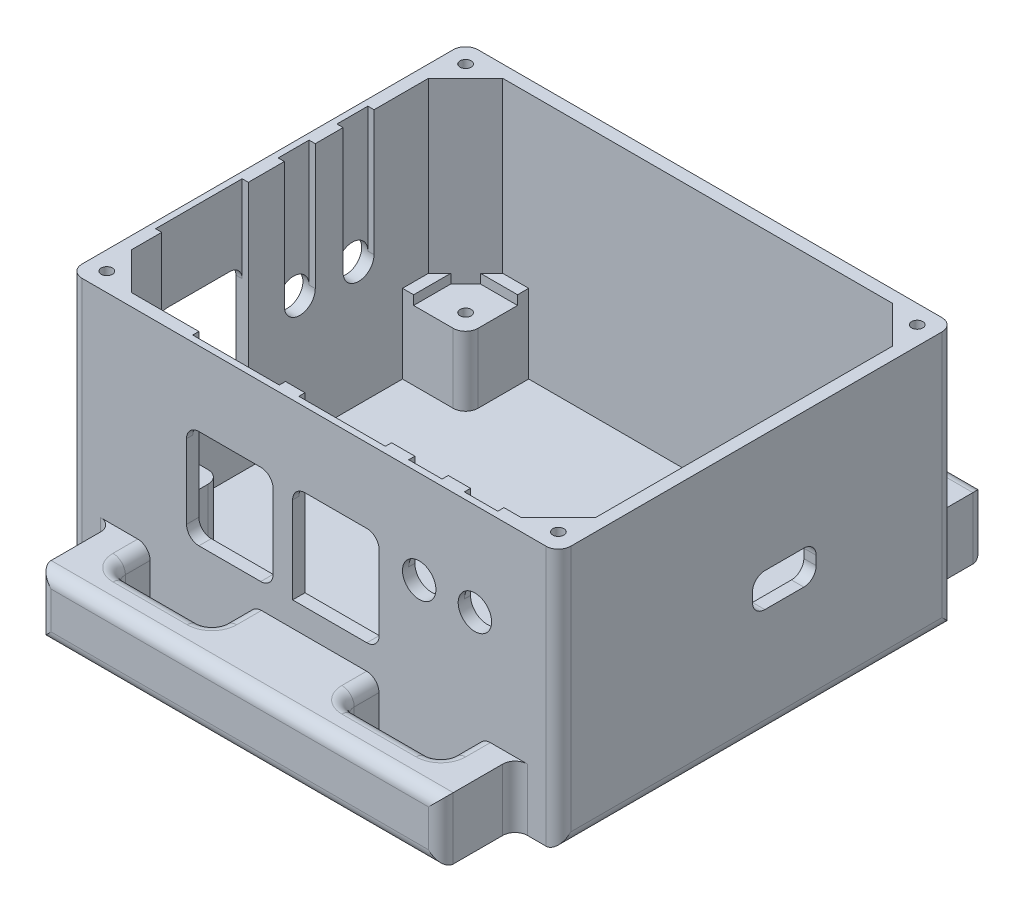
from build123d import *

# Parameters (mm, degrees)
SKETCH1_W             = 79
SKETCH1_H             = 64
BOSS_EXTRUDE1_DEPTH   = 2
SKETCH2_W             = 79
SKETCH2_H             = 64
SKETCH2_W_2           = 75
SKETCH2_H_2           = 60
BOSS_EXTRUDE2_DEPTH   = 40
BOSS_EXTRUDE3_DEPTH   = 40
SKETCH3_R             = 0.9
CUT_EXTRUDE2_DEPTH    = 10
SKETCH5_W             = 14
SKETCH5_H             = 1
SKETCH5_W_2           = 1
SKETCH5_H_2           = 14
CUT_EXTRUDE3_DEPTH    = 28
SKETCH6_W             = 14
SKETCH6_H             = 16
CUT_EXTRUDE4_DEPTH    = 2
SKETCH7_W             = 14
SKETCH7_H             = 16
CUT_EXTRUDE5_DEPTH    = 2
CUT_EXTRUDE7_DEPTH    = 1
SKETCH10_R            = 2.5
CUT_EXTRUDE8_DEPTH    = 3
SKETCH11_R            = 2.7
CUT_EXTRUDE9_DEPTH    = 3
SKETCH12_W            = 5.4
SKETCH12_H            = 15
CUT_EXTRUDE10_DEPTH   = 1
SKETCH13_W            = 10.3
SKETCH13_H            = 5.45
CUT_EXTRUDE11_DEPTH   = 2
FILLET1_R             = 2
FILLET2_R             = 2
FILLET5_R             = 2
FILLET6_R             = 2
FILLET7_R             = 2
FILLET8_R             = 2
FILLET9_R             = 2
FILLET10_R            = 2
FILLET11_R            = 2
FILLET12_R            = 2
FILLET13_R            = 2
FILLET14_R            = 2
FILLET15_R            = 2
FILLET16_R            = 2
FILLET17_R            = 2
FILLET18_R            = 2
FILLET19_R            = 2
SKETCH14_W            = 10.2
SKETCH14_H            = 10.2
SKETCH14_W_2          = 9.2
BOSS_EXTRUDE5_DEPTH   = 11.2
SKETCH15_R            = 0.9
CUT_EXTRUDE12_DEPTH   = 10
BOSS_EXTRUDE6_DEPTH   = 1.5
FILLET20_R            = 2
FILLET21_R            = 2
FILLET22_R            = 2
FILLET23_R            = 2
SKETCH18_W            = 65
SKETCH18_H            = 10
BOSS_EXTRUDE7_DEPTH   = 12
SKETCH19_W            = 16
SKETCH19_H            = 6
CUT_EXTRUDE13_DEPTH   = 12
FILLET24_R            = 2
FILLET25_R            = 2
FILLET26_R            = 2
FILLET27_R            = 2
FILLET28_R            = 2
FILLET24_OF_MIRROR8_R = 2
FILLET25_OF_MIRROR8_R = 2
FILLET26_OF_MIRROR8_R = 2
FILLET29_R            = 2
FILLET30_R            = 2


with BuildPart() as part:
    # Sketch1 → Boss-Extrude1 (new body)
    with BuildSketch(Plane(origin=(0, 0, 0), x_dir=(1, 0, 0), z_dir=(0, 1, 0))):
        Rectangle(SKETCH1_W, SKETCH1_H)
    extrude(amount=BOSS_EXTRUDE1_DEPTH)

    # Sketch2 → Boss-Extrude2 (add)
    with BuildSketch(Plane(origin=(0, 2, 0), x_dir=(1, 0, 0), z_dir=(0, 1, 0))):
        Rectangle(SKETCH2_W, SKETCH2_H)
        Rectangle(SKETCH2_W_2, SKETCH2_H_2, mode=Mode.SUBTRACT)
    extrude(amount=BOSS_EXTRUDE2_DEPTH)

    # Sketch4 → Boss-Extrude3 (add)
    with BuildSketch(Plane(origin=(0, 2, 0), x_dir=(1, 0, 0), z_dir=(0, 1, 0))):
        Polygon((-37.5, 24), (-31.5, 30), (-37.5, 30), align=None)
        Polygon((37.5, 30), (37.5, 24), (31.5, 30), align=None)
        Polygon((-37.5, -30), (-37.5, -24), (-31.5, -30), align=None)
        Polygon((37.5, -30), (31.5, -30), (37.5, -24), align=None)
    extrude(amount=BOSS_EXTRUDE3_DEPTH)

    # Sketch3 → Cut-Extrude2 (cut)
    with BuildSketch(Plane(origin=(0, 42, 0), x_dir=(1, 0, 0), z_dir=(0, 1, 0))):
        with Locations((-36.5, 29)):
            Circle(SKETCH3_R)
        with Locations((-36.5, -29)):
            Circle(SKETCH3_R)
        with Locations((36.5, -29)):
            Circle(SKETCH3_R)
        with Locations((36.5, 29)):
            Circle(SKETCH3_R)
    extrude(amount=-CUT_EXTRUDE2_DEPTH, mode=Mode.SUBTRACT)

    # Sketch5 → Cut-Extrude3 (cut)
    with BuildSketch(Plane(origin=(0, 42, 0), x_dir=(1, 0, 0), z_dir=(0, 1, 0))):
        with Locations((-13.611101866, -30.5)):
            Rectangle(SKETCH5_W, SKETCH5_H)
        with Locations((3.537080368, -30.5)):
            Rectangle(SKETCH5_W, SKETCH5_H)
        with Locations((-38, -12.120628691)):
            Rectangle(SKETCH5_W_2, SKETCH5_H_2)
    extrude(amount=-CUT_EXTRUDE3_DEPTH, mode=Mode.SUBTRACT)

    # Sketch6 → Cut-Extrude4 (cut)
    with BuildSketch(Plane(origin=(0, 0, 31), x_dir=(-1, 0, 0), z_dir=(0, 0, -1))):
        with Locations((13.611101866, 22)):
            Rectangle(SKETCH6_W, SKETCH6_H)
        with Locations((-3.537080368, 22)):
            Rectangle(SKETCH6_W, SKETCH6_H)
    extrude(amount=-CUT_EXTRUDE4_DEPTH, mode=Mode.SUBTRACT)

    # Sketch7 → Cut-Extrude5 (cut)
    with BuildSketch(Plane(origin=(-38.5, 0, 0), x_dir=(0, 0, -1), z_dir=(1, 0, 0))):
        with Locations((-12.120628691, 22)):
            Rectangle(SKETCH7_W, SKETCH7_H)
    extrude(amount=-CUT_EXTRUDE5_DEPTH, mode=Mode.SUBTRACT)

    # Sketch9 → Cut-Extrude7 (cut)
    with BuildSketch(Plane(origin=(-37.5, 0, 0), x_dir=(0, 0, -1), z_dir=(1, 0, 0))):
        with BuildLine():
            Line((0.7, 21.71), (0.7, 42))
            Line((0.7, 42), (5.7, 42))
            Line((5.7, 42), (5.7, 21.71))
            ThreePointArc((5.7, 21.71), (3.2, 19.21), (0.7, 21.71))
        make_face()
        with BuildLine():
            Line((10.2, 21.71), (10.2, 42))
            Line((10.2, 42), (15.2, 42))
            Line((15.2, 42), (15.2, 21.71))
            ThreePointArc((15.2, 21.71), (12.7, 19.21), (10.2, 21.71))
        make_face()
    extrude(amount=-CUT_EXTRUDE7_DEPTH, mode=Mode.SUBTRACT)

    # Sketch10 → Cut-Extrude8 (cut)
    with BuildSketch(Plane(origin=(-38.5, 0, 0), x_dir=(0, 0, -1), z_dir=(1, 0, 0))):
        with Locations((3.2, 21.71)):
            Circle(SKETCH10_R)
        with Locations((12.7, 21.71)):
            Circle(SKETCH10_R)
    extrude(amount=-CUT_EXTRUDE8_DEPTH, mode=Mode.SUBTRACT)

    # Sketch11 → Cut-Extrude9 (cut)
    with BuildSketch(Plane.XY.offset(32)):
        with Locations((17, 27)):
            Circle(SKETCH11_R)
        with Locations((26, 27)):
            Circle(SKETCH11_R)
    extrude(amount=-CUT_EXTRUDE9_DEPTH, mode=Mode.SUBTRACT)

    # Sketch12 → Cut-Extrude10 (cut)
    with BuildSketch(Plane(origin=(0, 0, 30), x_dir=(-1, 0, 0), z_dir=(0, 0, -1))):
        with Locations((-26, 34.5)):
            Rectangle(SKETCH12_W, SKETCH12_H)
        with Locations((-17, 34.5)):
            Rectangle(SKETCH12_W, SKETCH12_H)
    extrude(amount=-CUT_EXTRUDE10_DEPTH, mode=Mode.SUBTRACT)

    # Sketch13 → Cut-Extrude11 (cut)
    with BuildSketch(Plane.ZY.offset(-37.5)):
        with Locations((-4.52, 20.165)):
            Rectangle(SKETCH13_W, SKETCH13_H)
    extrude(amount=-CUT_EXTRUDE11_DEPTH, mode=Mode.SUBTRACT)

    # Fillet1
    fillet1_edges = [part.edges().sort_by_distance(p)[0] for p in [
        (-39.5, 0, 0),
        (-39.5, 21, -32),
        (-39.5, 21, 32),
    ]]
    fillet(fillet1_edges, radius=FILLET1_R)

    # Fillet2
    fillet2_edges = [part.edges().sort_by_distance(p)[0] for p in [
        (39.5, 0, 0),
        (39.5, 21, -32),
        (39.5, 21, 32),
    ]]
    fillet(fillet2_edges, radius=FILLET2_R)

    # Fillet5
    fillet5_edges = [part.edges().sort_by_distance(p)[0] for p in [
        (-20.611101866, 14, 31),
    ]]
    fillet(fillet5_edges, radius=FILLET5_R)

    # Fillet6
    fillet6_edges = [part.edges().sort_by_distance(p)[0] for p in [
        (-6.611101866, 30, 31.5),
    ]]
    fillet(fillet6_edges, radius=FILLET6_R)

    # Fillet7
    fillet7_edges = [part.edges().sort_by_distance(p)[0] for p in [
        (-20.611101866, 30, 31.5),
    ]]
    fillet(fillet7_edges, radius=FILLET7_R)

    # Fillet8
    fillet8_edges = [part.edges().sort_by_distance(p)[0] for p in [
        (-6.611101866, 14, 31),
    ]]
    fillet(fillet8_edges, radius=FILLET8_R)

    # Fillet9
    fillet9_edges = [part.edges().sort_by_distance(p)[0] for p in [
        (-3.462919632, 30, 31.5),
    ]]
    fillet(fillet9_edges, radius=FILLET9_R)

    # Fillet10
    fillet10_edges = [part.edges().sort_by_distance(p)[0] for p in [
        (10.537080368, 30, 31.5),
    ]]
    fillet(fillet10_edges, radius=FILLET10_R)

    # Fillet11
    fillet11_edges = [part.edges().sort_by_distance(p)[0] for p in [
        (10.537080368, 14, 31),
    ]]
    fillet(fillet11_edges, radius=FILLET11_R)

    # Fillet12
    fillet12_edges = [part.edges().sort_by_distance(p)[0] for p in [
        (-38.5, 14, 5.120628691),
    ]]
    fillet(fillet12_edges, radius=FILLET12_R)

    # Fillet13
    fillet13_edges = [part.edges().sort_by_distance(p)[0] for p in [
        (-38.5, 14, 19.120628691),
    ]]
    fillet(fillet13_edges, radius=FILLET13_R)

    # Fillet14
    fillet14_edges = [part.edges().sort_by_distance(p)[0] for p in [
        (-39, 30, 19.120628691),
    ]]
    fillet(fillet14_edges, radius=FILLET14_R)

    # Fillet15
    fillet15_edges = [part.edges().sort_by_distance(p)[0] for p in [
        (-39, 30, 5.120628691),
    ]]
    fillet(fillet15_edges, radius=FILLET15_R)

    # Fillet16
    fillet16_edges = [part.edges().sort_by_distance(p)[0] for p in [
        (38.5, 17.44, -9.67),
    ]]
    fillet(fillet16_edges, radius=FILLET16_R)

    # Fillet17
    fillet17_edges = [part.edges().sort_by_distance(p)[0] for p in [
        (38.5, 22.89, 0.63),
    ]]
    fillet(fillet17_edges, radius=FILLET17_R)

    # Fillet18
    fillet18_edges = [part.edges().sort_by_distance(p)[0] for p in [
        (38.5, 22.89, -9.67),
    ]]
    fillet(fillet18_edges, radius=FILLET18_R)

    # Fillet19
    fillet19_edges = [part.edges().sort_by_distance(p)[0] for p in [
        (38.5, 17.44, 0.63),
    ]]
    fillet(fillet19_edges, radius=FILLET19_R)

    # Sketch14 → Boss-Extrude5 (add)
    with BuildSketch(Plane(origin=(0, 2, 0), x_dir=(1, 0, 0), z_dir=(0, 1, 0))):
        with Locations((-32.4, -24.9)):
            Rectangle(SKETCH14_W, SKETCH14_H)
        with Locations((-32.4, 24.9)):
            Rectangle(SKETCH14_W, SKETCH14_H)
        with Locations((32.9, -24.9)):
            Rectangle(SKETCH14_W_2, SKETCH14_H)
        with Locations((32.9, 24.9)):
            Rectangle(SKETCH14_W_2, SKETCH14_H)
    extrude(amount=BOSS_EXTRUDE5_DEPTH)

    # Sketch15 → Cut-Extrude12 (cut)
    with BuildSketch(Plane(origin=(0, 13.2, 0), x_dir=(1, 0, 0), z_dir=(0, 1, 0))):
        with Locations((-30.5, -23)):
            Circle(SKETCH15_R)
        with Locations((-30.5, 23)):
            Circle(SKETCH15_R)
        with Locations((31.5, 23)):
            Circle(SKETCH15_R)
        with Locations((31.5, -23)):
            Circle(SKETCH15_R)
    extrude(amount=-CUT_EXTRUDE12_DEPTH, mode=Mode.SUBTRACT)

    # Sketch17 → Boss-Extrude6 (add)
    with BuildSketch(Plane(origin=(0, 13.2, 0), x_dir=(1, 0, 0), z_dir=(0, 1, 0))):
        Polygon((-37.5, 24), (-35.7, 25.8), (-35.7, 19.8), (-37.5, 19.8), align=None)
        Polygon((-37.5, -19.8), (-35.7, -19.8), (-35.7, -25.8), (-37.5, -24), align=None)
        Polygon((-27.3, -30), (-31.5, -30), (-33.3, -28.2), (-27.3, -28.2), align=None)
        Polygon((-27.3, 30), (-31.5, 30), (-33.3, 28.2), (-27.3, 28.2), align=None)
        Polygon((37.5, 19.8), (36.7, 19.8), (36.7, 24.8), (37.5, 24), align=None)
        Polygon((28.3, 30), (31.5, 30), (33.3, 28.2), (28.3, 28.2), align=None)
        Polygon((28.3, -30), (31.5, -30), (33.3, -28.2), (28.3, -28.2), align=None)
        Polygon((37.5, -19.8), (36.7, -19.8), (36.7, -24.8), (37.5, -24), align=None)
    extrude(amount=BOSS_EXTRUDE6_DEPTH)

    # Fillet20
    fillet20_edges = [part.edges().sort_by_distance(p)[0] for p in [
        (-27.3, 7.6, 19.8),
    ]]
    fillet(fillet20_edges, radius=FILLET20_R)

    # Fillet21
    fillet21_edges = [part.edges().sort_by_distance(p)[0] for p in [
        (-27.3, 7.6, -19.8),
    ]]
    fillet(fillet21_edges, radius=FILLET21_R)

    # Fillet22
    fillet22_edges = [part.edges().sort_by_distance(p)[0] for p in [
        (28.3, 7.6, -19.8),
    ]]
    fillet(fillet22_edges, radius=FILLET22_R)

    # Fillet23
    fillet23_edges = [part.edges().sort_by_distance(p)[0] for p in [
        (28.3, 7.6, 19.8),
    ]]
    fillet(fillet23_edges, radius=FILLET23_R)

    # Sketch18 → Boss-Extrude7 (add)
    with BuildSketch(Plane.XY.offset(32)):
        with Locations((0, 5)):
            Rectangle(SKETCH18_W, SKETCH18_H)
    boss_extrude7 = extrude(amount=BOSS_EXTRUDE7_DEPTH)

    # Sketch19 → Cut-Extrude13 (cut)
    with BuildSketch(Plane(origin=(0, 10, 0), x_dir=(1, 0, 0), z_dir=(0, 1, 0))):
        with Locations((-18.5, -35)):
            Rectangle(SKETCH19_W, SKETCH19_H)
        with Locations((18.5, -35)):
            Rectangle(SKETCH19_W, SKETCH19_H)
    cut_extrude13 = extrude(amount=-CUT_EXTRUDE13_DEPTH, mode=Mode.SUBTRACT)

    # Fillet24
    fillet24_edges = [part.edges().sort_by_distance(p)[0] for p in [
        (-26.5, 0, 35),
        (-26.5, 5, 38),
        (-10.5, 0, 35),
        (-18.5, 0, 38),
        (-10.5, 5, 38),
        (-26.5, 10, 35),
        (-18.5, 10, 38),
        (-10.5, 10, 35),
    ]]
    fillet(fillet24_edges, radius=FILLET24_R)

    # Fillet25
    fillet25_edges = [part.edges().sort_by_distance(p)[0] for p in [
        (10.5, 0, 35),
        (10.5, 5, 38),
        (26.5, 0, 35),
        (18.5, 0, 38),
        (26.5, 5, 38),
        (10.5, 10, 35),
        (18.5, 10, 38),
        (26.5, 10, 35),
    ]]
    fillet(fillet25_edges, radius=FILLET25_R)

    # Fillet26
    fillet26_edges = [part.edges().sort_by_distance(p)[0] for p in [
        (-32.5, 5, 44),
        (0, 0, 44),
        (32.5, 5, 44),
        (0, 10, 44),
    ]]
    fillet(fillet26_edges, radius=FILLET26_R)

    # Fillet27
    fillet27_edges = [part.edges().sort_by_distance(p)[0] for p in [
        (-32.5, 5, 32),
    ]]
    fillet(fillet27_edges, radius=FILLET27_R)

    # Fillet28
    fillet28_edges = [part.edges().sort_by_distance(p)[0] for p in [
        (32.5, 5, 32),
    ]]
    fillet(fillet28_edges, radius=FILLET28_R)

    # Mirror8: Boss-Extrude7, Cut-Extrude13 across plane
    add(boss_extrude7.mirror(Plane(origin=(0, 0, 0), x_dir=(1, 0, 0), z_dir=(0, 0, -1))))
    add(cut_extrude13.mirror(Plane(origin=(0, 0, 0), x_dir=(1, 0, 0), z_dir=(0, 0, -1))), mode=Mode.SUBTRACT)

    # Fillet24 of Mirror8
    fillet24_of_mirror8_edges = [part.edges().sort_by_distance(p)[0] for p in [
        (-26.5, 0, -35),
        (-26.5, 5, -38),
        (-10.5, 0, -35),
        (-18.5, 0, -38),
        (-10.5, 5, -38),
        (-26.5, 10, -35),
        (-18.5, 10, -38),
        (-10.5, 10, -35),
    ]]
    fillet(fillet24_of_mirror8_edges, radius=FILLET24_OF_MIRROR8_R)

    # Fillet25 of Mirror8
    fillet25_of_mirror8_edges = [part.edges().sort_by_distance(p)[0] for p in [
        (10.5, 0, -35),
        (10.5, 5, -38),
        (26.5, 0, -35),
        (18.5, 0, -38),
        (26.5, 5, -38),
        (10.5, 10, -35),
        (18.5, 10, -38),
        (26.5, 10, -35),
    ]]
    fillet(fillet25_of_mirror8_edges, radius=FILLET25_OF_MIRROR8_R)

    # Fillet26 of Mirror8
    fillet26_of_mirror8_edges = [part.edges().sort_by_distance(p)[0] for p in [
        (-32.5, 5, -44),
        (0, 0, -44),
        (32.5, 5, -44),
        (0, 10, -44),
    ]]
    fillet(fillet26_of_mirror8_edges, radius=FILLET26_OF_MIRROR8_R)

    # Fillet29
    fillet29_edges = [part.edges().sort_by_distance(p)[0] for p in [
        (32.5, 5, -32),
    ]]
    fillet(fillet29_edges, radius=FILLET29_R)

    # Fillet30
    fillet30_edges = [part.edges().sort_by_distance(p)[0] for p in [
        (-32.5, 5, -32),
    ]]
    fillet(fillet30_edges, radius=FILLET30_R)


solid = part.part
